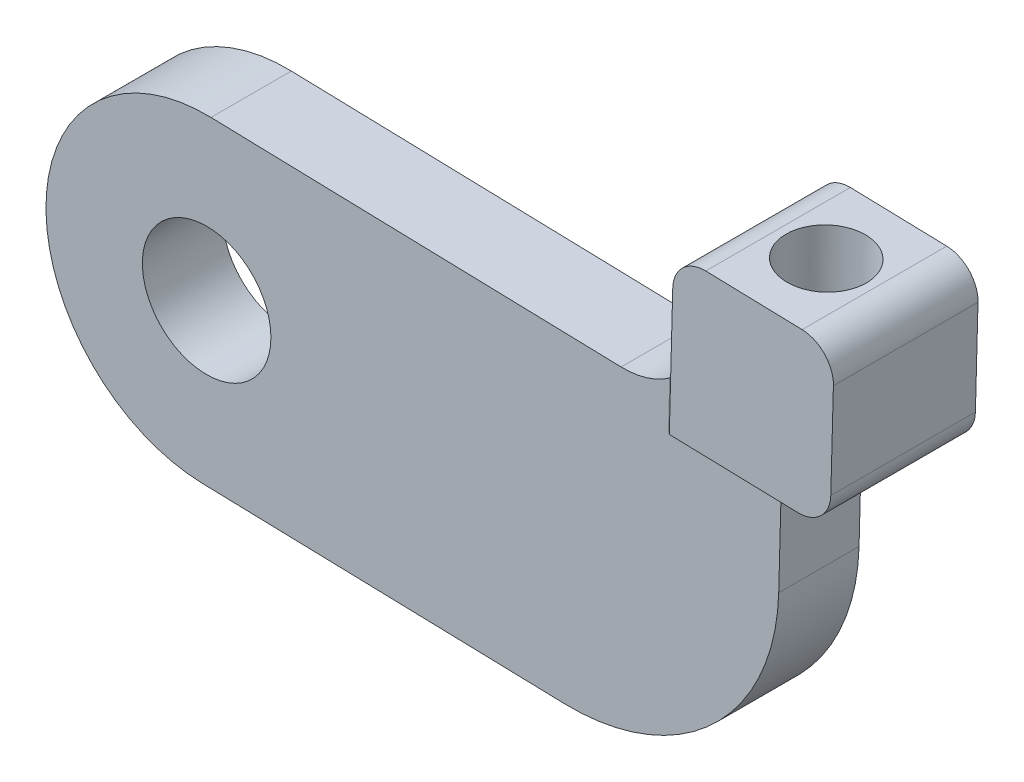
from build123d import *

# Parameters (mm, degrees)
SKETCH1_R           = 4
BOSS_EXTRUDE1_DEPTH = 5
SKETCH2_W           = 29.745771512
SKETCH2_H           = 31.069071225
CUT_EXTRUDE1_DEPTH  = 22.477415783
SKETCH3_W           = 10
SKETCH3_H           = 15
BOSS_EXTRUDE2_DEPTH = 10
FILLET1_R           = 13
FILLET2_R           = 5
FILLET3_R           = 2
FILLET4_R           = 2
SKETCH4_R           = 2.5
CUT_EXTRUDE2_DEPTH  = 7
SKETCH6_W           = 5.480044722
SKETCH6_H           = 16.421651107
CUT_EXTRUDE3_DEPTH  = 52.045615162


with BuildPart() as part:
    # Sketch1 → Boss-Extrude1 (new body)
    with BuildSketch(Plane.XY):
        with BuildLine():
            Line((-22.23071963, 10.602474367), (22.76928037, 9.390273126))
            ThreePointArc((22.76928037, 9.390273126), (32.496373747, -0.875380991), (22.23071963, -10.602474367))
            Line((22.23071963, -10.602474367), (-22.76928037, -9.390273126))
            ThreePointArc((-22.76928037, -9.390273126), (-32.496373747, 0.875380991), (-22.23071963, 10.602474367))
        make_face()
        with Locations((22.5, -0.606100621)):
            Circle(SKETCH1_R, mode=Mode.SUBTRACT)
        with Locations((-22.5, 0.606100621)):
            Circle(SKETCH1_R, mode=Mode.SUBTRACT)
    extrude(amount=BOSS_EXTRUDE1_DEPTH)

    # Sketch2 → Cut-Extrude1 (cut, through all)
    with BuildSketch(Plane(origin=(0.26928037, 9.996373747, 0), x_dir=(0.999637375, -0.026928037, 0), z_dir=(0.026928037, 0.999637375, 0))):
        with Locations((27.899171519, 0.562166988)):
            Rectangle(SKETCH2_W, SKETCH2_H)
    extrude(amount=-CUT_EXTRUDE1_DEPTH, mode=Mode.SUBTRACT)

    # Sketch3 → Boss-Extrude2 (add)
    with BuildSketch(Plane(origin=(0.26928037, 9.996373747, 0), x_dir=(0.999637375, -0.026928037, 0), z_dir=(0.026928037, 0.999637375, 0))):
        with Locations((13.026285763, -2.5)):
            Rectangle(SKETCH3_W, SKETCH3_H)
    extrude(amount=BOSS_EXTRUDE2_DEPTH)

    # Fillet1
    fillet1_edges = [part.edges().sort_by_distance(p)[0] for p in [
        (12.752281732, -10.347146052, 2.5),
    ]]
    fillet(fillet1_edges, radius=FILLET1_R)

    # Fillet2
    fillet2_edges = [part.edges().sort_by_distance(p)[0] for p in [
        (8.292655599, 9.780241626, 2.5),
    ]]
    fillet(fillet2_edges, radius=FILLET2_R)

    # Fillet3
    fillet3_edges = [part.edges().sort_by_distance(p)[0] for p in [
        (10.791749036, 9.712921534, 0),
        (10.791749036, 9.712921534, 5),
        (13.290842472, 9.645601441, 2.5),
        (8.359975692, 12.279335063, 0),
        (8.359975692, 12.279335063, 5),
    ]]
    fillet(fillet3_edges, radius=FILLET3_R)

    # Fillet4
    fillet4_edges = [part.edges().sort_by_distance(p)[0] for p in [
        (8.427295784, 14.7784285, -5),
        (8.427295784, 14.7784285, 10),
        (18.289029346, 9.510961256, 2.5),
        (18.423669531, 14.509148129, 10),
        (18.423669531, 14.509148129, -5),
        (8.561935969, 19.776615373, 2.5),
        (13.560122843, 19.641975188, 10),
        (18.558309716, 19.507335003, 2.5),
        (13.560122843, 19.641975188, -5),
    ]]
    fillet(fillet4_edges, radius=FILLET4_R)

    # Sketch4 → Cut-Extrude2 (cut)
    with BuildSketch(Plane(origin=(0.538560741, 19.992747493, 0), x_dir=(0.999637375, -0.026928037, 0), z_dir=(0.026928037, 0.999637375, 0))):
        with Locations((13.026285763, -2.5)):
            Circle(SKETCH4_R)
    extrude(amount=-CUT_EXTRUDE2_DEPTH, mode=Mode.SUBTRACT)

    # Sketch6 → Cut-Extrude3 (cut, through all)
    with BuildSketch(Plane(origin=(18.019748975, -0.485412491, 0), x_dir=(0, 0, -1), z_dir=(0.999637375, -0.026928037, 0))):
        with Locations((4.740022361, 14.542229601)):
            Rectangle(SKETCH6_W, SKETCH6_H)
        with Locations((-9.740022361, 14.542229601)):
            Rectangle(SKETCH6_W, SKETCH6_H)
    extrude(amount=-CUT_EXTRUDE3_DEPTH, mode=Mode.SUBTRACT)


solid = part.part
